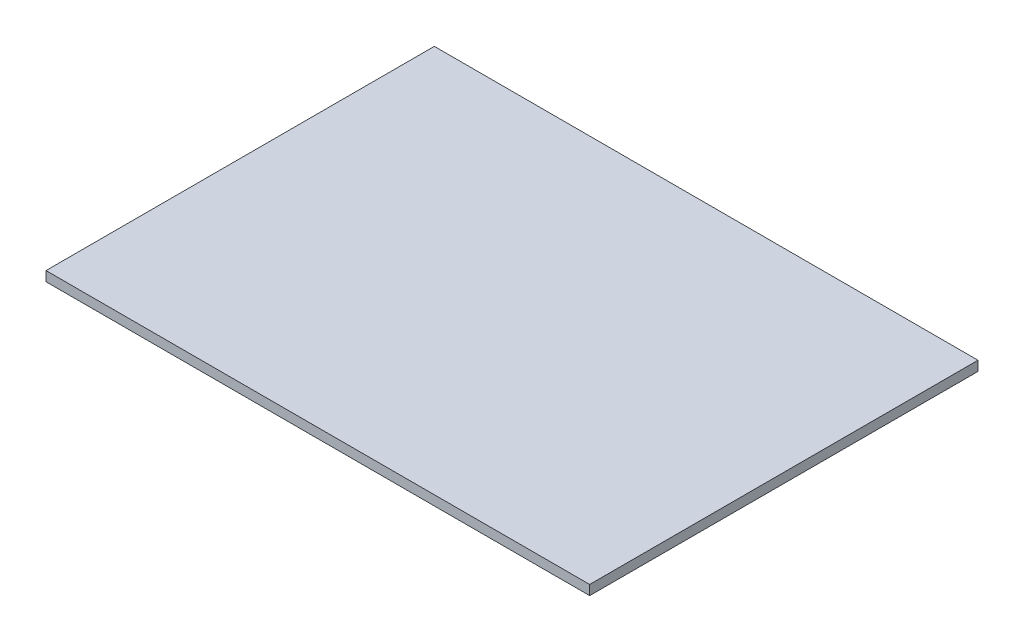
from build123d import *

# Parameters (mm, degrees)
SKETCH1_W           = 355.6
SKETCH1_H           = 254
BOSS_EXTRUDE1_DEPTH = 6.35


with BuildPart() as part:
    # Sketch1 → Boss-Extrude1 (new body)
    with BuildSketch(Plane(origin=(0, 0, 0), x_dir=(1, 0, 0), z_dir=(0, 1, 0))):
        with Locations((177.8, 127)):
            Rectangle(SKETCH1_W, SKETCH1_H)
    extrude(amount=BOSS_EXTRUDE1_DEPTH)


solid = part.part
